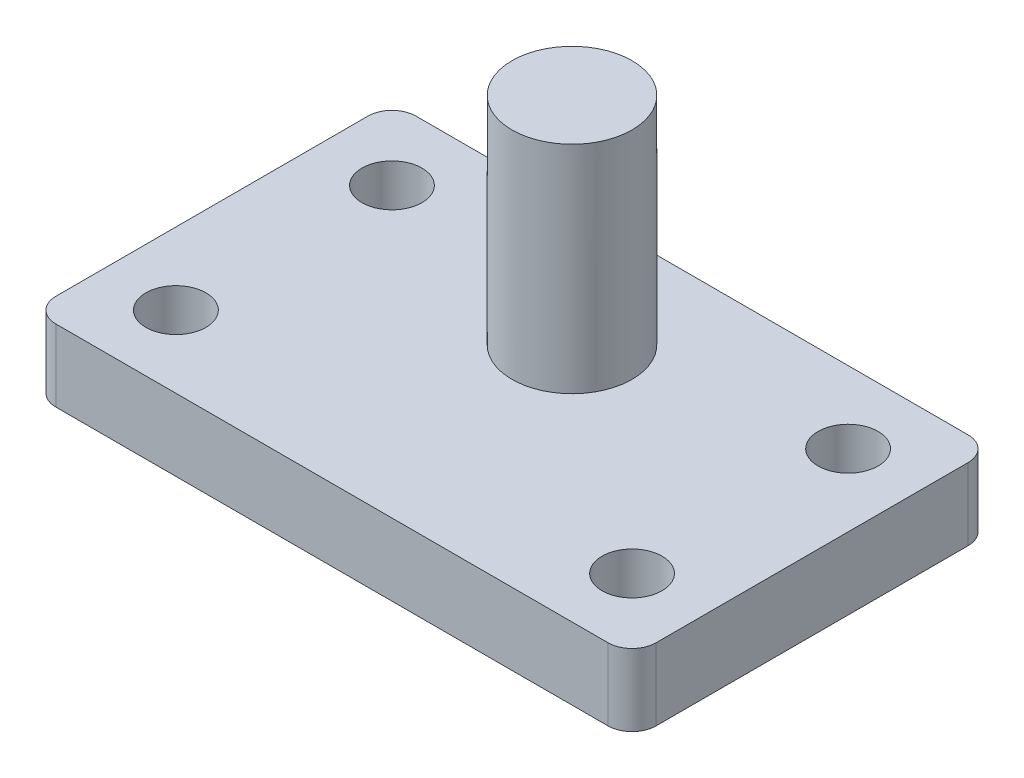
from build123d import *

# Parameters (mm, degrees)
BOSS_EXTRUDE1_DEPTH = 30
SKETCH2_R           = 25
BOSS_EXTRUDE2_DEPTH = 90
SKETCH3_R           = 12.5
CUT_EXTRUDE1_DEPTH  = 31


with BuildPart() as part:
    # Sketch1 → Boss-Extrude1 (new body)
    with BuildSketch(Plane(origin=(0, 0, 0), x_dir=(1, 0, 0), z_dir=(0, 1, 0))):
        with BuildLine():
            Line((115, -75), (-115, -75))
            ThreePointArc((-115, -75), (-122.071067812, -72.071067812), (-125, -65))
            Line((-125, -65), (-125, 65))
            ThreePointArc((-125, 65), (-122.071067812, 72.071067812), (-115, 75))
            Line((-115, 75), (115, 75))
            ThreePointArc((115, 75), (122.071067812, 72.071067812), (125, 65))
            Line((125, 65), (125, -65))
            ThreePointArc((125, -65), (122.071067812, -72.071067812), (115, -75))
        make_face()
    extrude(amount=BOSS_EXTRUDE1_DEPTH)

    # Sketch2 → Boss-Extrude2 (add)
    with BuildSketch(Plane(origin=(0, 30, 0), x_dir=(1, 0, 0), z_dir=(0, 1, 0))):
        with Locations((0, 25)):
            Circle(SKETCH2_R)
    extrude(amount=BOSS_EXTRUDE2_DEPTH)

    # Sketch3 → Cut-Extrude1 (cut, through all)
    with BuildSketch(Plane(origin=(0, 30, 0), x_dir=(1, 0, 0), z_dir=(0, 1, 0))):
        with Locations((-95, 45)):
            Circle(SKETCH3_R)
        with Locations((95, 45)):
            Circle(SKETCH3_R)
        with Locations((95, -45)):
            Circle(SKETCH3_R)
        with Locations((-95, -45)):
            Circle(SKETCH3_R)
    extrude(amount=-CUT_EXTRUDE1_DEPTH, mode=Mode.SUBTRACT)


solid = part.part
